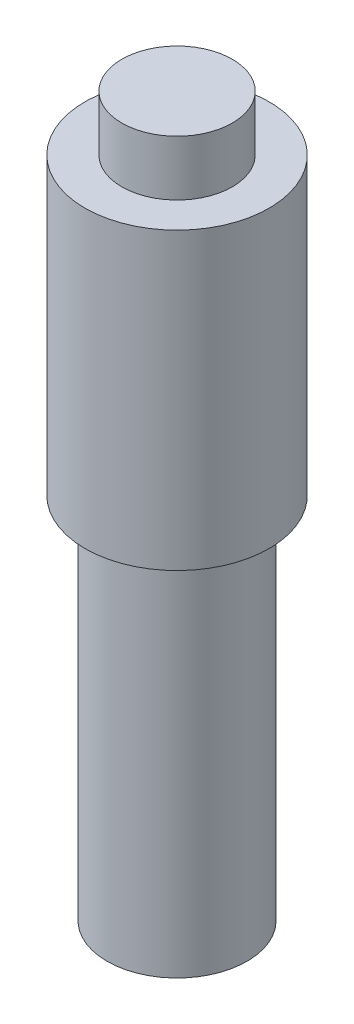
from build123d import *


with BuildPart() as part:
    # 草圖1 → 旋轉1 (revolve)
    with BuildSketch(Plane.XY):
        Polygon((0, 0), (3, 0), (3, -3), (5, -3), (5, -19), (3.8, -19), (3.8, -39), (0, -39), align=None)
    revolve(axis=Axis((0, 46.155431861, 0), (0, -1, 0)))


solid = part.part
